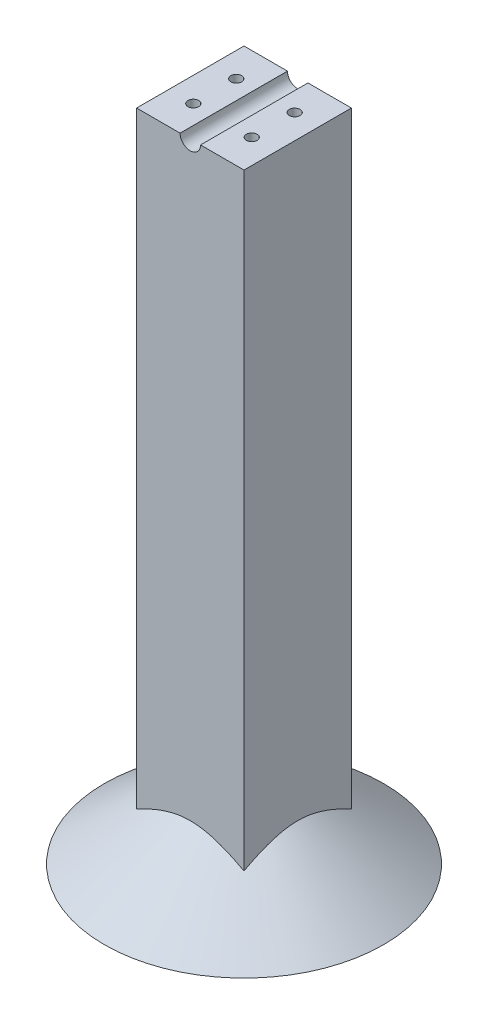
from build123d import *

# Parameters (mm, degrees)
SKETCH1_W                       = 25
SKETCH1_H                       = 25
BOSS_EXTRUDE1_DEPTH             = 152.4
CUT_EXTRUDE1_REACH              = 47
SKETCH3_R                       = 2.38125
SKETCH4_R                       = 1
CUT_EXTRUDE2_DEPTH              = 10
TAP_DRILL_FOR_M3X0_5_TAP1_D     = 2.5
TAP_DRILL_FOR_M3X0_5_TAP1_DEPTH = 15
TAP_DRILL_FOR_M3X0_5_TAP1_TIP   = 0.751075774


with BuildPart() as part:
    # Sketch1 → Boss-Extrude1 (new body)
    with BuildSketch(Plane(origin=(0, 0, 0), x_dir=(1, 0, 0), z_dir=(0, 1, 0))):
        Rectangle(SKETCH1_W, SKETCH1_H)
    extrude(amount=-BOSS_EXTRUDE1_DEPTH)

    # Sketch2 → Revolve1 (revolve)
    with BuildSketch(Plane.XY):
        Polygon((12.5, -137.4), (32.5, -152.4), (12.5, -152.4), align=None)
    revolve(axis=Axis((0, -152.4, 0), (0, 1, 0)))

    # Sketch3 → Cut-Extrude1 (cut, up to next)
    with BuildSketch(Plane.XY.offset(12.5), mode=Mode.PRIVATE) as cut_extrude1_sk1:
        Circle(SKETCH3_R)
    cut_extrude1_tool1 = extrude(cut_extrude1_sk1.sketch, amount=-CUT_EXTRUDE1_REACH, mode=Mode.PRIVATE) & part.part
    add(cut_extrude1_tool1.solids().sort_by_distance((0, 0, 12.5))[0], mode=Mode.SUBTRACT)

    # Sketch4 → Cut-Extrude2 (cut)
    with BuildSketch(Plane(origin=(0, 0, 0), x_dir=(1, 0, 0), z_dir=(0, 1, 0))):
        with Locations((-6.8, 5)):
            Circle(SKETCH4_R)
        with Locations((6.8, 5)):
            Circle(SKETCH4_R)
        with Locations((6.8, -5)):
            Circle(SKETCH4_R)
        with Locations((-6.8, -5)):
            Circle(SKETCH4_R)
    extrude(amount=-CUT_EXTRUDE2_DEPTH, mode=Mode.SUBTRACT)

    # Tap Drill for M3x0.5 Tap1
    with Locations(Plane(origin=(0, 0, 0), x_dir=(1, 0, 0), z_dir=(0, 1, 0))):
        with Locations((-6.8, -5), (-6.8, 5), (6.8, 5), (6.8, -5)):
            Hole(TAP_DRILL_FOR_M3X0_5_TAP1_D / 2, depth=TAP_DRILL_FOR_M3X0_5_TAP1_DEPTH)
            with Locations((0, 0, -(TAP_DRILL_FOR_M3X0_5_TAP1_DEPTH + TAP_DRILL_FOR_M3X0_5_TAP1_TIP / 2))):  # 118° drill point
                Cone(0, TAP_DRILL_FOR_M3X0_5_TAP1_D / 2, TAP_DRILL_FOR_M3X0_5_TAP1_TIP, mode=Mode.SUBTRACT)


solid = part.part
